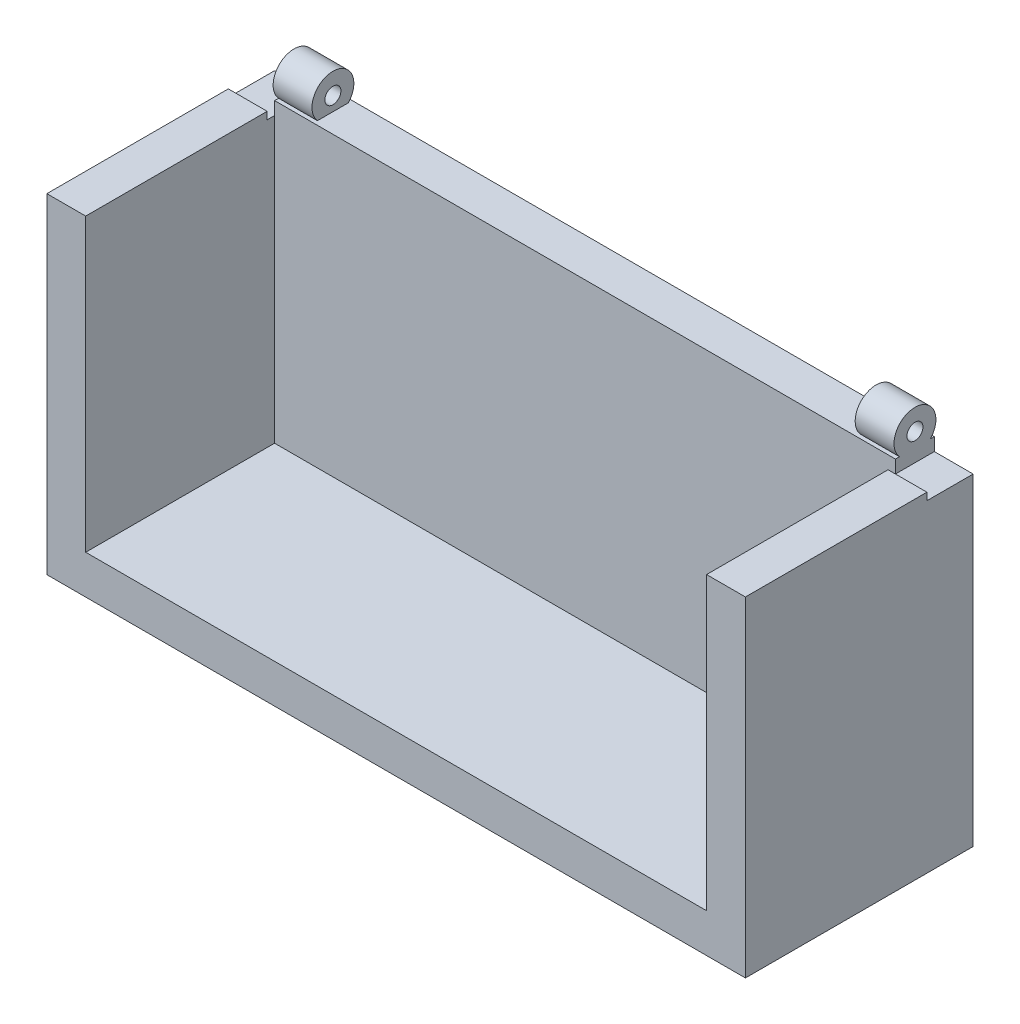
from build123d import *

# Parameters (mm, degrees)
SKETCH1_W            = 269.8
SKETCH1_H            = 142.5
BOSS_EXTRUDE2_DEPTH  = 15
SKETCH2_W            = 239.8
SKETCH2_H            = 112.5
CUT_EXTRUDE1_DEPTH   = 5
BOSS_EXTRUDE3_DEPTH  = 75
SKETCH7_R            = 8.089056034
SKETCH7_R_2          = 3.089056034
BOSS_EXTRUDE4_DEPTH  = 15
BOSS_EXTRUDE5_DEPTH  = 15
SKETCH15_W           = 15
SKETCH15_H           = 15
CUT_EXTRUDE2_DEPTH   = 5
SKETCH16_W           = 269.8
SKETCH16_H           = 127.5
CUT_EXTRUDE3_DEPTH   = 49
SKETCH17_W           = 269.8
SKETCH17_H           = 15
BOSS_EXTRUDE6_DEPTH  = 39.6
BOSS_EXTRUDE8_DEPTH  = 72.95
SKETCH20_W           = 15
SKETCH20_H           = 70.089840249
BOSS_EXTRUDE9_DEPTH  = 2.85
SKETCH21_W           = 15
SKETCH21_H           = 70.0898402
BOSS_EXTRUDE10_DEPTH = 2.85


with BuildPart() as part:
    # Sketch1 → Boss-Extrude2 (new body)
    with BuildSketch(Plane(origin=(0, 0, 0), x_dir=(1, 0, 0), z_dir=(0, 1, 0))):
        with Locations((-23.308401977, 12.292504119)):
            Rectangle(SKETCH1_W, SKETCH1_H)
    extrude(amount=BOSS_EXTRUDE2_DEPTH)

    # Sketch2 → Cut-Extrude1 (cut)
    with BuildSketch(Plane(origin=(0, 15, 0), x_dir=(1, 0, 0), z_dir=(0, 1, 0))):
        with Locations((-23.308401977, 12.292504119)):
            Rectangle(SKETCH2_W, SKETCH2_H)
    extrude(amount=-CUT_EXTRUDE1_DEPTH, mode=Mode.SUBTRACT)

    # Sketch3 → Boss-Extrude3 (add)
    with BuildSketch(Plane(origin=(0, 15, 0), x_dir=(1, 0, 0), z_dir=(0, 1, 0))):
        Polygon((-143.208401977, 68.542504119), (-158.208401977, 68.542504119), (-158.208401977, 83.542504119), (111.591598023, 83.542504119), (111.591598023, 68.542504119), align=None)
    extrude(amount=BOSS_EXTRUDE3_DEPTH)

    # Sketch7 → Boss-Extrude4 (add)
    with BuildSketch(Plane(origin=(-143.208401977, 0, 0), x_dir=(0, 0, -1), z_dir=(1, 0, 0))):
        with Locations((76.070987498, 95.45383679)):
            Circle(SKETCH7_R)
        with Locations((76.070987498, 95.45383679)):
            Circle(SKETCH7_R_2, mode=Mode.SUBTRACT)
    extrude(amount=BOSS_EXTRUDE4_DEPTH)

    # Sketch12 → Boss-Extrude5 (add)
    with BuildSketch(Plane.ZY.offset(-96.591598023)):
        with BuildLine():
            ThreePointArc((-76.070987498, 103.542892824), (-84.160043532, 95.45383679), (-76.070987498, 87.364780756))
            Line((-76.070987498, 87.364780756), (-76.070987498, 92.364780756))
            ThreePointArc((-76.070987498, 92.364780756), (-79.160043532, 95.45383679), (-76.070987498, 98.542892824))
            Line((-76.070987498, 98.542892824), (-76.070987498, 103.542892824))
        make_face()
        with BuildLine():
            Line((-76.070987498, 92.364780756), (-76.070987498, 87.364780756))
            ThreePointArc((-76.070987498, 87.364780756), (-70.351161122, 89.734010415), (-67.981931463, 95.45383679))
            ThreePointArc((-67.981931463, 95.45383679), (-70.351161122, 101.173663165), (-76.070987498, 103.542892824))
            Line((-76.070987498, 103.542892824), (-76.070987498, 98.542892824))
            ThreePointArc((-76.070987498, 98.542892824), (-73.886695028, 97.638129259), (-72.981931463, 95.45383679))
            ThreePointArc((-72.981931463, 95.45383679), (-73.886695028, 93.269544321), (-76.070987498, 92.364780756))
        make_face()
    extrude(amount=BOSS_EXTRUDE5_DEPTH)

    # Sketch15 → Cut-Extrude2 (cut)
    with BuildSketch(Plane(origin=(0, 90, 0), x_dir=(1, 0, 0), z_dir=(0, 1, 0))):
        with Locations((-150.708401977, 76.042504119)):
            Rectangle(SKETCH15_W, SKETCH15_H)
        with Locations((104.091598023, 76.042504119)):
            Rectangle(SKETCH15_W, SKETCH15_H)
    extrude(amount=-CUT_EXTRUDE2_DEPTH, mode=Mode.SUBTRACT)

    # Sketch16 → Cut-Extrude3 (cut)
    with BuildSketch(Plane(origin=(0, 25, 0), x_dir=(1, 0, 0), z_dir=(0, 1, 0))):
        with Locations((-23.308401977, 4.792504119)):
            Rectangle(SKETCH16_W, SKETCH16_H)
    extrude(amount=-CUT_EXTRUDE3_DEPTH, mode=Mode.SUBTRACT)

    # Sketch17 → Boss-Extrude6 (add)
    with BuildSketch(Plane.XZ):
        with Locations((-23.308401977, -76.042504119)):
            Rectangle(SKETCH17_W, SKETCH17_H)
    extrude(amount=BOSS_EXTRUDE6_DEPTH)

    # Sketch19 → Boss-Extrude8 (add)
    with BuildSketch(Plane.XY.offset(-68.542504119)):
        Polygon((-158.208401977, 85), (-158.208401977, -39.6), (111.591598023, -39.6), (111.591598023, 85), (96.591598023, 85), (96.591598023, -24.6), (-143.208401977, -24.6), (-143.208401977, 85), align=None)
    extrude(amount=BOSS_EXTRUDE8_DEPTH)

    # Sketch20 → Boss-Extrude9 (add)
    with BuildSketch(Plane(origin=(0, 85, 0), x_dir=(1, 0, 0), z_dir=(0, 1, 0))):
        with Locations((-150.708401977, 30.637424243)):
            Rectangle(SKETCH20_W, SKETCH20_H)
    extrude(amount=BOSS_EXTRUDE9_DEPTH)

    # Sketch21 → Boss-Extrude10 (add)
    with BuildSketch(Plane(origin=(0, 85, 0), x_dir=(1, 0, 0), z_dir=(0, 1, 0))):
        with Locations((104.091598023, 30.637424219)):
            Rectangle(SKETCH21_W, SKETCH21_H)
    extrude(amount=BOSS_EXTRUDE10_DEPTH)


solid = part.part
